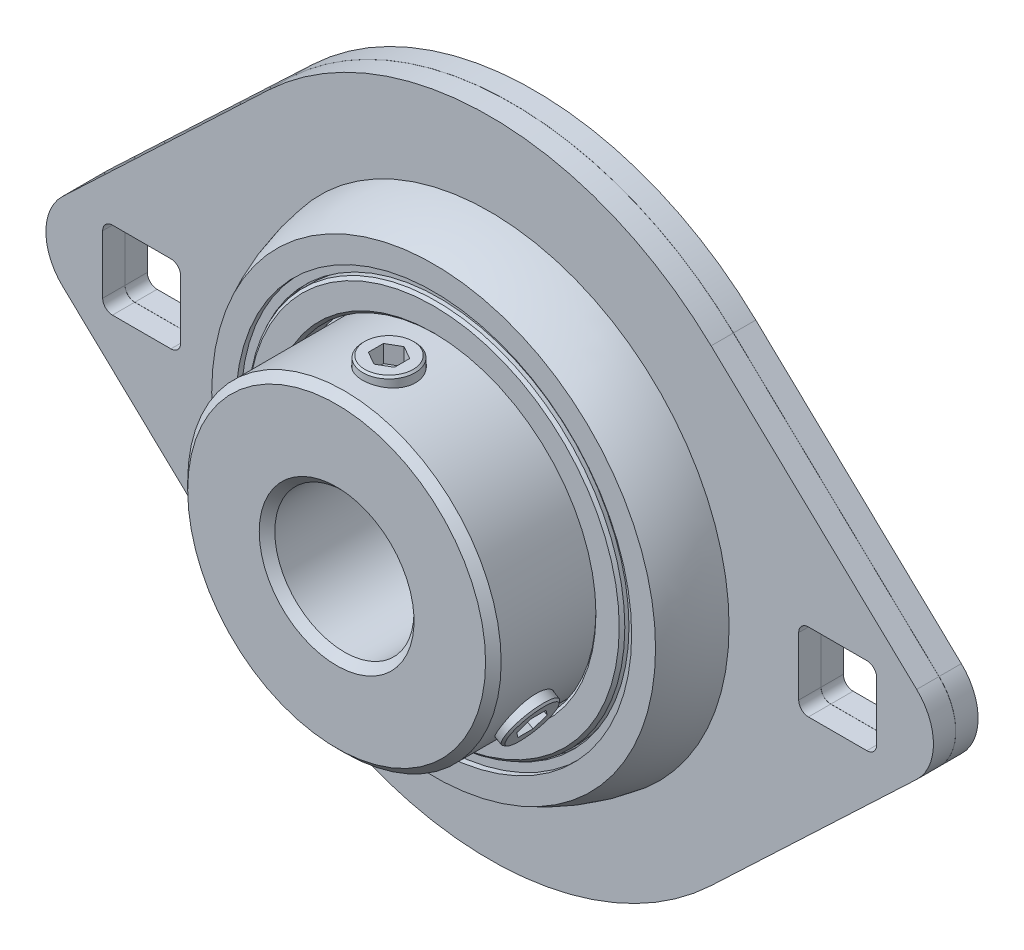
from build123d import *

# Parameters (mm, degrees)
CHAMFER3_SIZE           = 0.254
CHAMFER4_SIZE           = 0.254
CIRPATTERN1_COUNT       = 4
EXTRUDE1_DEPTH          = 2.032
EXTRUDE2_DEPTH          = 2.032
SKETCH6_W               = 7.112
SKETCH6_H               = 7.112
CUT_EXTRUDE1_DEPTH      = 16.99946
CUT_EXTRUDE1_DEPTH_BACK = 8.1501001
FILLET1_R               = 0.889
FILLET2_R               = 0.889
CHAMFER1_SIZE           = 0.7112
SKETCH7_W               = 2.413
SKETCH7_H               = 15.0622
CHAMFER2_SIZE           = 0.1778
CUT_EXTRUDE2_DEPTH      = 1.592865993
CIRPATTERN2_COUNT       = 2
CIRPATTERN2_ANGLE       = 120
CIRPATTERN3_COUNT       = 2
CIRPATTERN3_ANGLE       = 120


with BuildPart() as part:
    # Sketch1 → Revolve1 (revolve)
    with BuildSketch(Plane(origin=(0, 0, 0), x_dir=(0, 0, -1), z_dir=(1, 0, 0))):
        with BuildLine():
            Line((-15.99946, 6.35), (5.99948, 6.35))
            Line((5.99948, 6.35), (5.99948, 14.3002))
            Line((5.99948, 14.3002), (2.676895127, 14.3002))
            ThreePointArc((2.676895127, 14.3002), (0, 13.143865), (-2.676895127, 14.3002))
            Line((-2.676895127, 14.3002), (-15.99946, 14.3002))
            Line((-15.99946, 14.3002), (-15.99946, 6.35))
        make_face()
        with BuildLine():
            Line((0.00508, 29.3751), (0.00508, 19.94467783))
            ThreePointArc((0.00508, 19.94467783), (2.6098494, 19.692804865), (5.1181, 18.946519034))
            Line((5.1181, 18.946519034), (5.1181, 14.5542))
            Line((5.1181, 14.5542), (7.1501, 14.5542))
            Line((7.1501, 14.5542), (7.1501, 17.189591421))
            Line((7.1501, 17.189591421), (6.1341, 17.189591421))
            Line((6.1341, 17.189591421), (6.1341, 17.316591421))
            Line((6.1341, 17.316591421), (6.6421, 17.316591421))
            Line((6.6421, 17.316591421), (6.6421, 18.068055227))
            Line((6.6421, 18.068055227), (7.1501, 18.068055227))
            Line((7.1501, 18.068055227), (7.1501, 20.247544718))
            ThreePointArc((7.1501, 20.247544718), (4.662503256, 21.266483118), (2.03708, 21.844))
            Line((2.03708, 21.844), (2.03708, 29.3751))
            Line((2.03708, 29.3751), (0.00508, 29.3751))
        make_face()
        with BuildLine():
            Line((-2.03708, 29.3751), (-0.00508, 29.3751))
            Line((-0.00508, 29.3751), (-0.00508, 19.94467783))
            ThreePointArc((-0.00508, 19.94467783), (-2.6098494, 19.692804865), (-5.1181, 18.946519034))
            Line((-5.1181, 18.946519034), (-5.1181, 14.5542))
            Line((-5.1181, 14.5542), (-7.1501, 14.5542))
            Line((-7.1501, 14.5542), (-7.1501, 17.189591421))
            Line((-7.1501, 17.189591421), (-6.1341, 17.189591421))
            Line((-6.1341, 17.189591421), (-6.1341, 17.316591421))
            Line((-6.1341, 17.316591421), (-6.6421, 17.316591421))
            Line((-6.6421, 17.316591421), (-6.6421, 18.068055227))
            Line((-6.6421, 18.068055227), (-7.1501, 18.068055227))
            Line((-7.1501, 18.068055227), (-7.1501, 20.247544718))
            ThreePointArc((-7.1501, 20.247544718), (-4.662503256, 21.266483118), (-2.03708, 21.844))
            Line((-2.03708, 21.844), (-2.03708, 29.3751))
        make_face()
    revolve(axis=Axis((0, 0, 5.1181), (0, 0, -1)))

    # Chamfer3
    chamfer3_edges = [part.edges().sort_by_distance(p)[0] for p in [
        (0, -17.189591421, 7.1501),
        (0, -14.5542, 7.1501),
    ]]
    chamfer(chamfer3_edges, length=CHAMFER3_SIZE)

    # Chamfer4
    chamfer4_edges = [part.edges().sort_by_distance(p)[0] for p in [
        (0, -14.5542, -7.1501),
        (0, -17.189591421, -7.1501),
    ]]
    chamfer(chamfer4_edges, length=CHAMFER4_SIZE)

    # Sketch4 → Extrude1 (add)
    with BuildSketch(Plane.XY.offset(2.03708)):
        with BuildLine():
            Line((-20.202896864, 21.324620942), (-38.958083746, 3.556))
            ThreePointArc((-38.958083746, 3.556), (-40.4876, 0), (-38.958083746, -3.556))
            Line((-38.958083746, -3.556), (-20.202896864, -21.324620942))
            ThreePointArc((-20.202896864, -21.324620942), (-29.3751, 0), (-20.202896864, 21.324620942))
        make_face()
        with BuildLine():
            Line((20.202896864, -21.324620942), (38.958083746, -3.556))
            ThreePointArc((38.958083746, -3.556), (40.4876, 0), (38.958083746, 3.556))
            Line((38.958083746, 3.556), (20.202896864, 21.324620942))
            ThreePointArc((20.202896864, 21.324620942), (29.3751, 0), (20.202896864, -21.324620942))
        make_face()
    extrude(amount=-EXTRUDE1_DEPTH)

    # Sketch5 → Extrude2 (add)
    with BuildSketch(Plane(origin=(0, 0, -2.03708), x_dir=(-1, 0, 0), z_dir=(0, 0, -1))):
        with BuildLine():
            Line((20.202896864, 21.324620942), (38.958083746, 3.556))
            ThreePointArc((38.958083746, 3.556), (40.4876, 0), (38.958083746, -3.556))
            Line((38.958083746, -3.556), (20.202896864, -21.324620942))
            ThreePointArc((20.202896864, -21.324620942), (29.3751, 0), (20.202896864, 21.324620942))
        make_face()
        with BuildLine():
            Line((-20.202896864, -21.324620942), (-38.958083746, -3.556))
            ThreePointArc((-38.958083746, -3.556), (-40.4876, 0), (-38.958083746, 3.556))
            Line((-38.958083746, 3.556), (-20.202896864, 21.324620942))
            ThreePointArc((-20.202896864, 21.324620942), (-29.3751, 0), (-20.202896864, -21.324620942))
        make_face()
    extrude(amount=-EXTRUDE2_DEPTH)

    # Sketch6 → Cut-Extrude1 (cut, two sides)
    with BuildSketch(Plane.XY) as cut_extrude1_sk:
        with Locations((31.75, 0)):
            Rectangle(SKETCH6_W, SKETCH6_H)
        with Locations((-31.75, 0)):
            Rectangle(SKETCH6_W, SKETCH6_H)
    extrude(amount=CUT_EXTRUDE1_DEPTH, mode=Mode.SUBTRACT)
    extrude(cut_extrude1_sk.sketch, amount=-CUT_EXTRUDE1_DEPTH_BACK, mode=Mode.SUBTRACT)

    # Fillet1
    fillet1_edges = [part.edges().sort_by_distance(p)[0] for p in [
        (35.306, 3.556, -1.02108),
        (35.306, -3.556, -1.02108),
        (28.194, -3.556, -1.02108),
        (28.194, 3.556, -1.02108),
        (-28.194, -3.556, -1.02108),
        (-35.306, -3.556, -1.02108),
        (-35.306, 3.556, -1.02108),
        (-28.194, 3.556, -1.02108),
    ]]
    fillet(fillet1_edges, radius=FILLET1_R)

    # Fillet2
    fillet2_edges = [part.edges().sort_by_distance(p)[0] for p in [
        (35.306, 3.556, 1.02108),
        (35.306, -3.556, 1.02108),
        (28.194, -3.556, 1.02108),
        (28.194, 3.556, 1.02108),
        (-28.194, -3.556, 1.02108),
        (-35.306, -3.556, 1.02108),
        (-35.306, 3.556, 1.02108),
        (-28.194, 3.556, 1.02108),
    ]]
    fillet(fillet2_edges, radius=FILLET2_R)

    # Chamfer1
    chamfer1_edges = [part.edges().sort_by_distance(p)[0] for p in [
        (0, -14.3002, 15.99946),
        (0, -6.35, -5.99948),
        (0, -6.35, 15.99946),
    ]]
    chamfer(chamfer1_edges, length=CHAMFER1_SIZE)

    # Sketch7 → Cut-Revolve2 (revolve, cut)
    with BuildSketch(Plane(origin=(0, 0, 0), x_dir=(0, 0, -1), z_dir=(1, 0, 0))):
        with Locations((-12.42568, 7.5311)):
            Rectangle(SKETCH7_W, SKETCH7_H)
    cut_revolve2 = revolve(axis=Axis((0, 0, 11.21918), (0, 1, 0)), mode=Mode.SUBTRACT)

    # CirPattern2: Cut-Revolve2 ×2 about axis
    cirpattern2_axis = Axis((0, 0, 0), (0, 0, -1))
    for i in range(1, CIRPATTERN2_COUNT):
        add(cut_revolve2.rotate(cirpattern2_axis, i * CIRPATTERN2_ANGLE / (CIRPATTERN2_COUNT - 1)), mode=Mode.SUBTRACT)


with BuildPart() as body_2:
    # Sketch3 → Revolve3 (revolve)
    with BuildSketch(Plane(origin=(0, 0, 0), x_dir=(0, 0, -1), z_dir=(1, 0, 0))):
        with BuildLine():
            Line((0, 20.420965), (0, 13.220065))
            ThreePointArc((0, 13.220065), (3.60045, 16.820515), (0, 20.420965))
        make_face()
    revolve(axis=Axis((0, 20.420965, 0), (0, -1, 0)))


with BuildPart() as cirpattern1_1:
    # CirPattern1: pattern copy
    add(body_2.part.rotate(Axis((0, 0, 0), (0, 0, 1)), 1 * 360 / CIRPATTERN1_COUNT))


with BuildPart() as cirpattern1_2:
    # CirPattern1: pattern copy
    add(body_2.part.rotate(Axis((0, 0, 0), (0, 0, 1)), 2 * 360 / CIRPATTERN1_COUNT))


with BuildPart() as cirpattern1_3:
    # CirPattern1: pattern copy
    add(body_2.part.rotate(Axis((0, 0, 0), (0, 0, 1)), 3 * 360 / CIRPATTERN1_COUNT))


with BuildPart() as body_6:
    # Sketch8 → Revolve4 (revolve)
    with BuildSketch(Plane(origin=(0, 0, 0), x_dir=(0, 0, -1), z_dir=(1, 0, 0))):
        Polygon((-13.60678, 15.0622), (-13.60678, 7.097870034), (-13.334577569, 6.35), (-11.21918, 6.35), (-11.21918, 15.0622), (-12.015046667, 15.0622), (-12.810913333, 15.0622), align=None)
    revolve(axis=Axis((0, 6.35, 11.21918), (0, 1, 0)))

    # Chamfer2
    chamfer2_edges = [body_6.edges().sort_by_distance(p)[0] for p in [
        (0, 15.0622, 8.83158),
    ]]
    chamfer(chamfer2_edges, length=CHAMFER2_SIZE)

    # Sketch9 → Cut-Extrude2 (cut)
    with BuildSketch(Plane(origin=(0, 15.0622, 0), x_dir=(-1, 0, 0), z_dir=(0, 1, 0))):
        Polygon((0, 9.840698497), (1.1938, 10.529939249), (1.1938, 11.908420751), (0, 12.597661503), (-1.1938, 11.908420751), (-1.1938, 10.529939249), align=None)
    extrude(amount=-CUT_EXTRUDE2_DEPTH, mode=Mode.SUBTRACT)


with BuildPart() as cirpattern3_1:
    # CirPattern3: pattern copy
    add(body_6.part.rotate(Axis((0, 0, 0), (0, 0, -1)), 1 * CIRPATTERN3_ANGLE / (CIRPATTERN3_COUNT - 1)))


solid = Compound([part.part, body_2.part, cirpattern1_1.part, cirpattern1_2.part, cirpattern1_3.part, body_6.part, cirpattern3_1.part])
